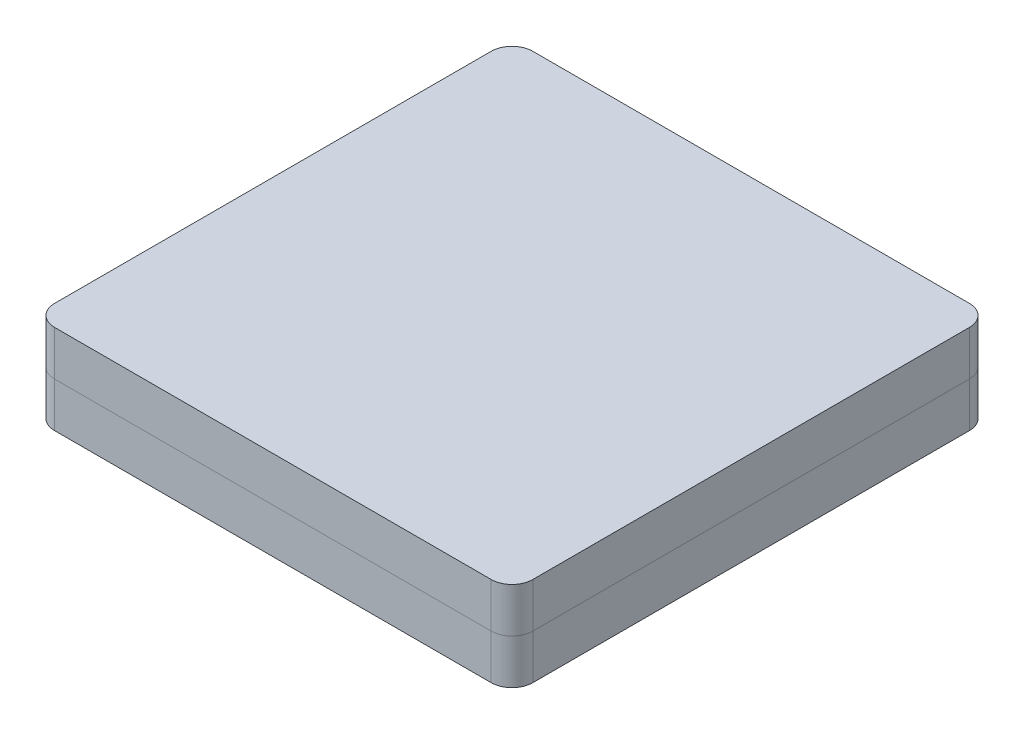
from build123d import *

# Parameters (mm, degrees)
BOSS_EXTRUDE1_DEPTH = 4.3


with BuildPart() as part:
    # Sketch1 → Boss-Extrude1 (new body)
    with BuildSketch(Plane(origin=(0, 0, 0), x_dir=(1, 0, 0), z_dir=(0, 1, 0))):
        with BuildLine():
            Line((-10.5, -11.5), (10.5, -11.5))
            ThreePointArc((10.5, -11.5), (11.207106781, -11.207106781), (11.5, -10.5))
            Line((11.5, -10.5), (11.5, 10.5))
            ThreePointArc((11.5, 10.5), (11.207106781, 11.207106781), (10.5, 11.5))
            Line((10.5, 11.5), (-10.5, 11.5))
            ThreePointArc((-10.5, 11.5), (-11.207106781, 11.207106781), (-11.5, 10.5))
            Line((-11.5, 10.5), (-11.5, -10.5))
            ThreePointArc((-11.5, -10.5), (-11.207106781, -11.207106781), (-10.5, -11.5))
        make_face()
    extrude(amount=BOSS_EXTRUDE1_DEPTH)


with BuildPart() as body_2:
    # Split1: the piece on the far side of the plane
    add(part.part)
    split(bisect_by=Plane.ZX.offset(2.15), keep=Keep.BOTTOM)


with BuildPart() as part_1:
    add(part.part)

    # Split1
    split(bisect_by=Plane.ZX.offset(2.15), keep=Keep.TOP)


solid = Compound([body_2.part, part_1.part])
